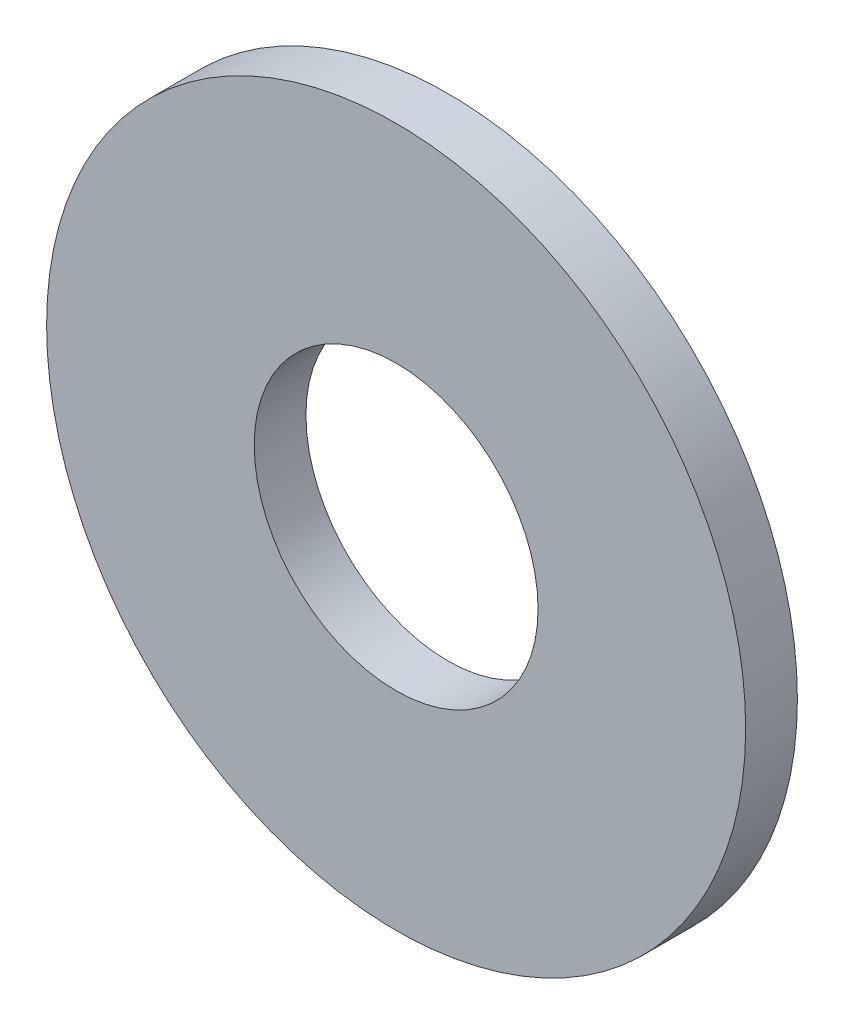
from build123d import *

# Parameters (mm, degrees)
SKETCH1_W = 3.7592
SKETCH1_H = 15.0876


with BuildPart() as part:
    # Sketch1 → Revolve1 (revolve)
    with BuildSketch(Plane(origin=(0, 0, 0), x_dir=(0, 0, -1), z_dir=(1, 0, 0))):
        with Locations((-1.8796, 17.8562)):
            Rectangle(SKETCH1_W, SKETCH1_H)
    revolve(axis=Axis((0, 0, 34.925), (0, 0, -1)))


solid = part.part
